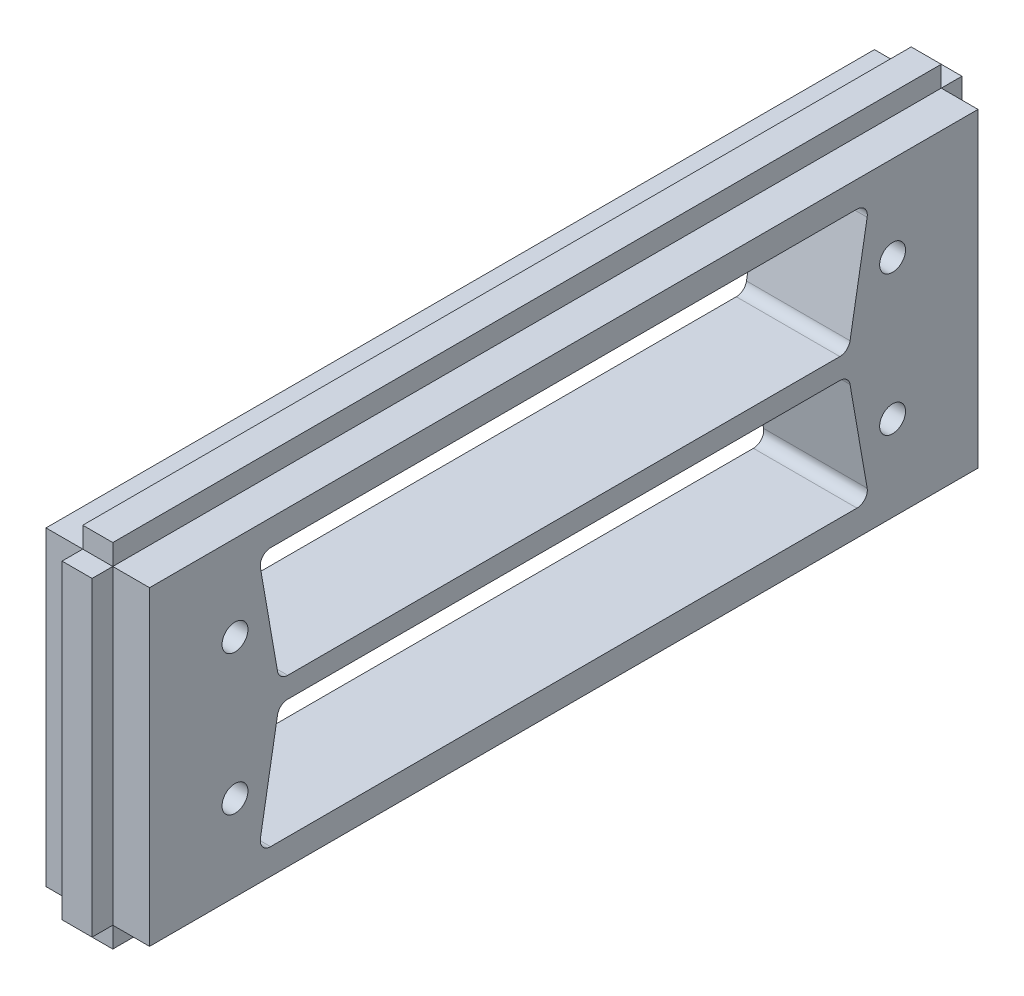
from build123d import *

# Parameters (mm, degrees)
MAKERBEAMFIX_DEPTH            = 40
SKETCH4_R                     = 1.25
HOLEFORHARTINGCONNECTOR_DEPTH = 11
FILLET1_R                     = 1
FILLET1_OF_MIRROR1_R          = 1
SKETCH5_W                     = 2.9
SKETCH5_H                     = 30
MAKERBEAMFIXLEFT_DEPTH        = 2
SKETCH6_W                     = 2.9
SKETCH6_H                     = 30
MAKERBEAMFIXRIGHT_DEPTH       = 2


with BuildPart() as part:
    # Sketch1 → MakerBeamFix (new body, symmetric)
    with BuildSketch(Plane.XY):
        Polygon((-5, -15), (-1.45, -15), (-1.45, -17), (1.45, -17), (1.45, -15), (5, -15), (5, 15), (1.45, 15), (1.45, 17), (-1.45, 17), (-1.45, 15), (-5, 15), align=None)
    extrude(amount=MAKERBEAMFIX_DEPTH, both=True)

    # Sketch4 → HoleForHartingConnector (cut, through all)
    with BuildSketch(Plane.ZY.offset(5)):
        with Locations((-31.75, 6.75)):
            Circle(SKETCH4_R)
        with Locations((31.75, 6.75)):
            Circle(SKETCH4_R)
        Polygon((-29.5, 12.5), (29.5, 12.5), (27.5, 1), (-27.5, 1), align=None)
    holeforhartingconnector = extrude(amount=-HOLEFORHARTINGCONNECTOR_DEPTH, mode=Mode.SUBTRACT)

    # Fillet1
    fillet1_edges = [part.edges().sort_by_distance(p)[0] for p in [
        (0, 1, -27.5),
        (0, 12.5, -29.5),
        (0, 12.5, 29.5),
        (0, 1, 27.5),
    ]]
    fillet(fillet1_edges, radius=FILLET1_R)

    # Mirror1: HoleForHartingConnector across plane
    add(holeforhartingconnector.mirror(Plane.ZX), mode=Mode.SUBTRACT)

    # Fillet1 of Mirror1
    fillet1_of_mirror1_edges = [part.edges().sort_by_distance(p)[0] for p in [
        (0, -1, -27.5),
        (0, -12.5, -29.5),
        (0, -12.5, 29.5),
        (0, -1, 27.5),
    ]]
    fillet(fillet1_of_mirror1_edges, radius=FILLET1_OF_MIRROR1_R)

    # Sketch5 → MakerBeamFixLeft (add)
    with BuildSketch(Plane.XY.offset(40)):
        Rectangle(SKETCH5_W, SKETCH5_H)
    extrude(amount=MAKERBEAMFIXLEFT_DEPTH)

    # Sketch6 → MakerBeamFixRight (add)
    with BuildSketch(Plane(origin=(0, 0, -40), x_dir=(-1, 0, 0), z_dir=(0, 0, -1))):
        Rectangle(SKETCH6_W, SKETCH6_H)
    extrude(amount=MAKERBEAMFIXRIGHT_DEPTH)


solid = part.part
